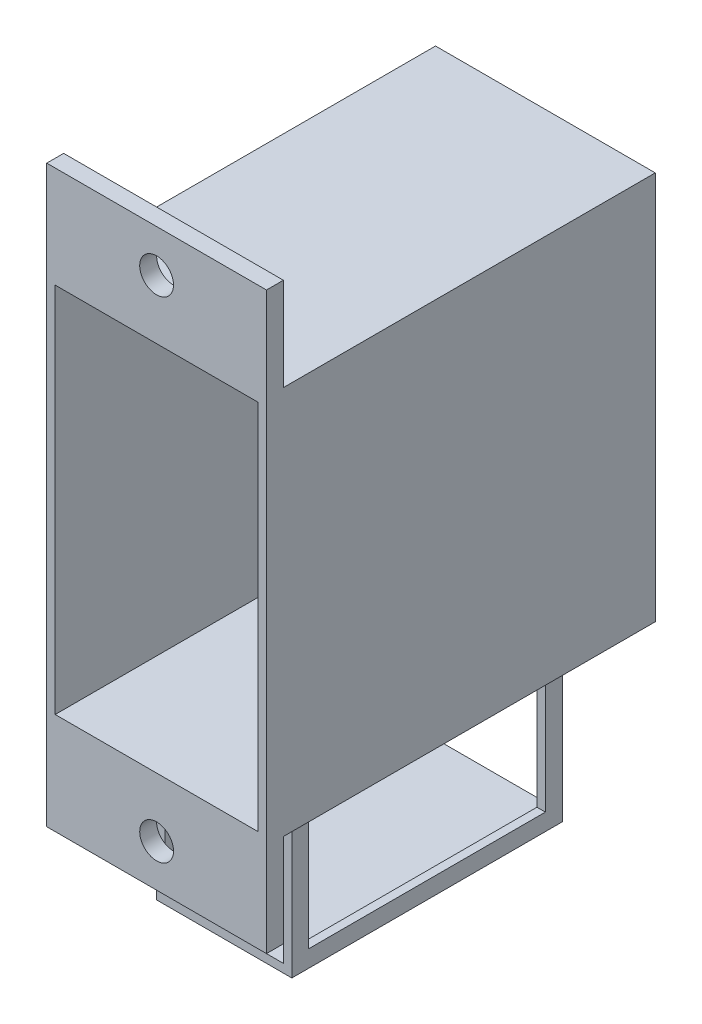
from build123d import *

# Parameters (mm, degrees)
SKETCH1_W           = 13
SKETCH1_H           = 23
BOSS_EXTRUDE1_DEPTH = 23
CUT_EXTRUDE1_REACH  = 28.524
SKETCH1_3_W         = 12
SKETCH1_3_H         = 22
SKETCH2_W           = 13
SKETCH2_H           = 5.5
SKETCH2_R           = 1
BOSS_EXTRUDE2_DEPTH = 1
SKETCH4_W           = 8
SKETCH4_H           = 16
BOSS_EXTRUDE3_DEPTH = 10
CUT_EXTRUDE2_REACH  = 35.189
SKETCH5_W           = 14
SKETCH5_H           = 8
CUT_EXTRUDE3_REACH  = 32.075
SKETCH6_W           = 7
SKETCH6_H           = 9


with BuildPart() as part:
    # Sketch1 → Boss-Extrude1 (new body)
    with BuildSketch(Plane.XY):
        Rectangle(SKETCH1_W, SKETCH1_H)
    extrude(amount=BOSS_EXTRUDE1_DEPTH)

    # Sketch1_3 → Cut-Extrude1 (cut, up to next)
    with BuildSketch(Plane.XY, mode=Mode.PRIVATE) as cut_extrude1_sk1:
        Rectangle(SKETCH1_3_W, SKETCH1_3_H)
    cut_extrude1_tool1 = extrude(cut_extrude1_sk1.sketch, amount=CUT_EXTRUDE1_REACH, mode=Mode.PRIVATE) & part.part
    add(cut_extrude1_tool1.solids().sort_by_distance((0, 0, 0))[0], mode=Mode.SUBTRACT)

    # Sketch2 → Boss-Extrude2 (add)
    # profile 1 of 2: a face of its own
    with BuildSketch(Plane.XY.offset(23)):
        with Locations((0, 14.25)):
            Rectangle(SKETCH2_W, SKETCH2_H)
        with Locations((0, 14.5)):
            Circle(SKETCH2_R, mode=Mode.SUBTRACT)
    # profile 2 of 2: a face of its own
    with BuildSketch(Plane.XY.offset(23)):
        with Locations((0, -14.25)):
            Rectangle(SKETCH2_W, SKETCH2_H)
        with Locations((0, -14.5)):
            Circle(SKETCH2_R, mode=Mode.SUBTRACT)
    extrude(amount=-BOSS_EXTRUDE2_DEPTH)

    # Sketch4 → Boss-Extrude3 (add)
    with BuildSketch(Plane(origin=(0, -11.5, 0), x_dir=(-1, 0, 0), z_dir=(0, -1, 0))):
        with Locations((0, -11)):
            Rectangle(SKETCH4_W, SKETCH4_H)
    extrude(amount=BOSS_EXTRUDE3_DEPTH)

    # Sketch5 → Cut-Extrude2 (cut, up to next)
    with BuildSketch(Plane(origin=(4, 0, 0), x_dir=(0, 0, -1), z_dir=(1, 0, 0)), mode=Mode.PRIVATE) as cut_extrude2_sk1:
        with Locations((-11, -16.5)):
            Rectangle(SKETCH5_W, SKETCH5_H)
    cut_extrude2_tool1 = extrude(cut_extrude2_sk1.sketch, amount=-CUT_EXTRUDE2_REACH, mode=Mode.PRIVATE) & part.part
    add(cut_extrude2_tool1.solids().sort_by_distance((4, -16.5, 11))[0], mode=Mode.SUBTRACT)

    # Sketch6 → Cut-Extrude3 (cut, up to next)
    with BuildSketch(Plane(origin=(0, 0, 3), x_dir=(-1, 0, 0), z_dir=(0, 0, -1)), mode=Mode.PRIVATE) as cut_extrude3_sk1:
        with Locations((0, -16.5)):
            Rectangle(SKETCH6_W, SKETCH6_H)
    cut_extrude3_tool1 = extrude(cut_extrude3_sk1.sketch, amount=-CUT_EXTRUDE3_REACH, mode=Mode.PRIVATE) & part.part
    add(cut_extrude3_tool1.solids().sort_by_distance((0, -16.5, 3))[0], mode=Mode.SUBTRACT)


solid = part.part
